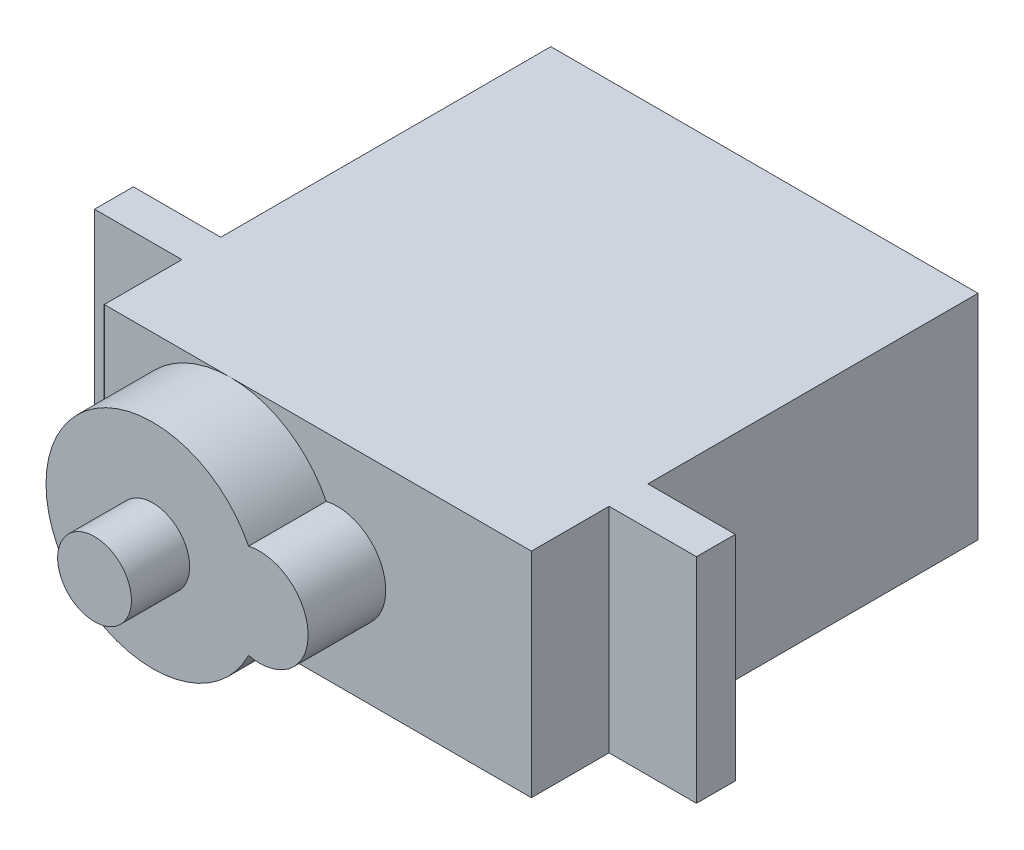
from build123d import *

# Parameters (mm, degrees)
SKETCH2_W           = 31
SKETCH2_H           = 11
SKETCH2_R           = 1.9
BOSS_EXTRUDE1_DEPTH = 23
SKETCH2_2_R         = 1.9
BOSS_EXTRUDE2_DEPTH = 30
SKETCH3_W           = 4.5
SKETCH3_H           = 11
CUT_EXTRUDE1_DEPTH  = 4
CUT_EXTRUDE2_START  = -6
SKETCH3_5_W         = 4.5
SKETCH3_5_H         = 11
CUT_EXTRUDE2_DEPTH  = 23.275431031
BOSS_EXTRUDE3_DEPTH = 4


with BuildPart() as part:
    # Sketch2 → Boss-Extrude1 (new body)
    with BuildSketch(Plane.XY):
        Rectangle(SKETCH2_W, SKETCH2_H)
        with Locations((-4.5, 0)):
            Circle(SKETCH2_R, mode=Mode.SUBTRACT)
    extrude(amount=BOSS_EXTRUDE1_DEPTH)

    # Sketch2_2 → Boss-Extrude2 (add)
    with BuildSketch(Plane.XY):
        with Locations((-4.5, 0)):
            Circle(SKETCH2_2_R)
    extrude(amount=BOSS_EXTRUDE2_DEPTH)

    # Sketch3 → Cut-Extrude1 (cut)
    with BuildSketch(Plane.XY.offset(23)):
        with Locations((-13.25, 0)):
            Rectangle(SKETCH3_W, SKETCH3_H)
        with Locations((13.25, 0)):
            Rectangle(SKETCH3_W, SKETCH3_H)
    extrude(amount=-CUT_EXTRUDE1_DEPTH, mode=Mode.SUBTRACT)

    # Sketch3_5 → Cut-Extrude2 (cut, through all)
    with BuildSketch(Plane.XY.offset(23).offset(CUT_EXTRUDE2_START)):
        with Locations((-13.25, 0)):
            Rectangle(SKETCH3_5_W, SKETCH3_5_H)
        with Locations((13.25, 0)):
            Rectangle(SKETCH3_5_W, SKETCH3_5_H)
    extrude(amount=-CUT_EXTRUDE2_DEPTH, mode=Mode.SUBTRACT)

    # Sketch4 → Boss-Extrude3 (add)
    with BuildSketch(Plane.XY.offset(23)):
        with BuildLine():
            ThreePointArc((0.431818182, 2.434577873), (-10, 0), (0.431818182, -2.434577873))
            ThreePointArc((0.431818182, -2.434577873), (3.5, 0), (0.431818182, 2.434577873))
        make_face()
    extrude(amount=BOSS_EXTRUDE3_DEPTH)


solid = part.part
